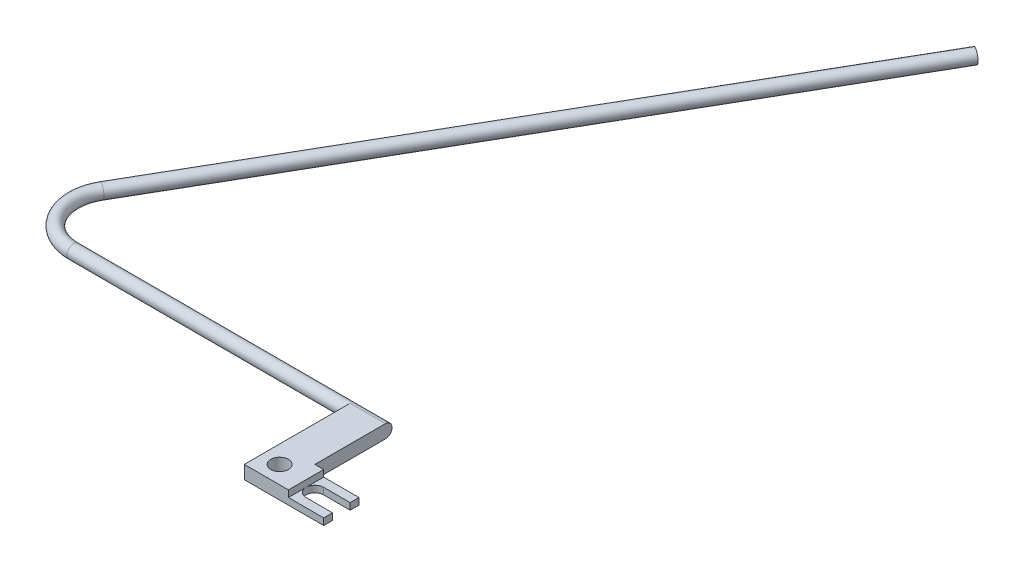
from build123d import *

# Parameters (mm, degrees)
SKETCH1_R           = 2
BOSS_EXTRUDE1_DEPTH = 3
SKETCH3_R           = 1.5
SKETCH4_W           = 8
SKETCH4_H           = 1.5
CUT_EXTRUDE1_DEPTH  = 10
CUT_EXTRUDE2_DEPTH  = 10


with BuildPart() as part:
    # Sketch1 → Boss-Extrude1 (new body)
    with BuildSketch(Plane(origin=(0, 0, 0), x_dir=(1, 0, 0), z_dir=(0, 1, 0))):
        with BuildLine():
            Line((0, 0), (0, 20))
            Line((0, 20), (-8, 20))
            Line((-8, 20), (-8, -8))
            Line((-8, -8), (10, -8))
            Line((10, -8), (10, -6))
            Line((10, -6), (4, -6))
            ThreePointArc((4, -6), (2, -4), (4, -2))
            Line((4, -2), (10, -2))
            Line((10, -2), (10, 0))
            Line((10, 0), (0, 0))
        make_face()
        with Locations((-4, -4)):
            Circle(SKETCH1_R, mode=Mode.SUBTRACT)
    extrude(amount=BOSS_EXTRUDE1_DEPTH)

    # Sweep1: sweep along a path in Sketch2
    with BuildLine(Plane(origin=(0, 1.5, 0), x_dir=(1, 0, 0), z_dir=(0, 1, 0))) as sweep1_path:
        Line((-8, 16), (-70.679491924, 16))
        ThreePointArc((-70.679491924, 16), (-79.339745962, 21), (-79.339745962, 31))
        Line((-79.339745962, 31), (-6.839745962, 156.573683549))
    # Sketch3 → Sweep1 (sweep)
    with BuildSketch(Plane.ZY.offset(8)):
        with Locations((-15.996391196, 1.5)):
            Circle(SKETCH3_R)
    sweep(path=sweep1_path.line)

    # Sketch4 → Cut-Extrude1 (cut)
    with BuildSketch(Plane(origin=(0, 0, 0), x_dir=(-1, 0, 0), z_dir=(0, 0, -1))):
        with Locations((-6, 2.25)):
            Rectangle(SKETCH4_W, SKETCH4_H)
    extrude(amount=-CUT_EXTRUDE1_DEPTH, mode=Mode.SUBTRACT)

    # Sketch5 → Cut-Extrude2 (cut)
    with BuildSketch(Plane.ZY.offset(8)):
        with BuildLine():
            Line((-15.996391196, 3), (-20, 3))
            Line((-20, 3), (-20, 0))
            Line((-20, 0), (-15.996391196, 0))
            ThreePointArc((-15.996391196, 0), (-17.496391196, 1.5), (-15.996391196, 3))
        make_face()
    extrude(amount=-CUT_EXTRUDE2_DEPTH, mode=Mode.SUBTRACT)


solid = part.part
